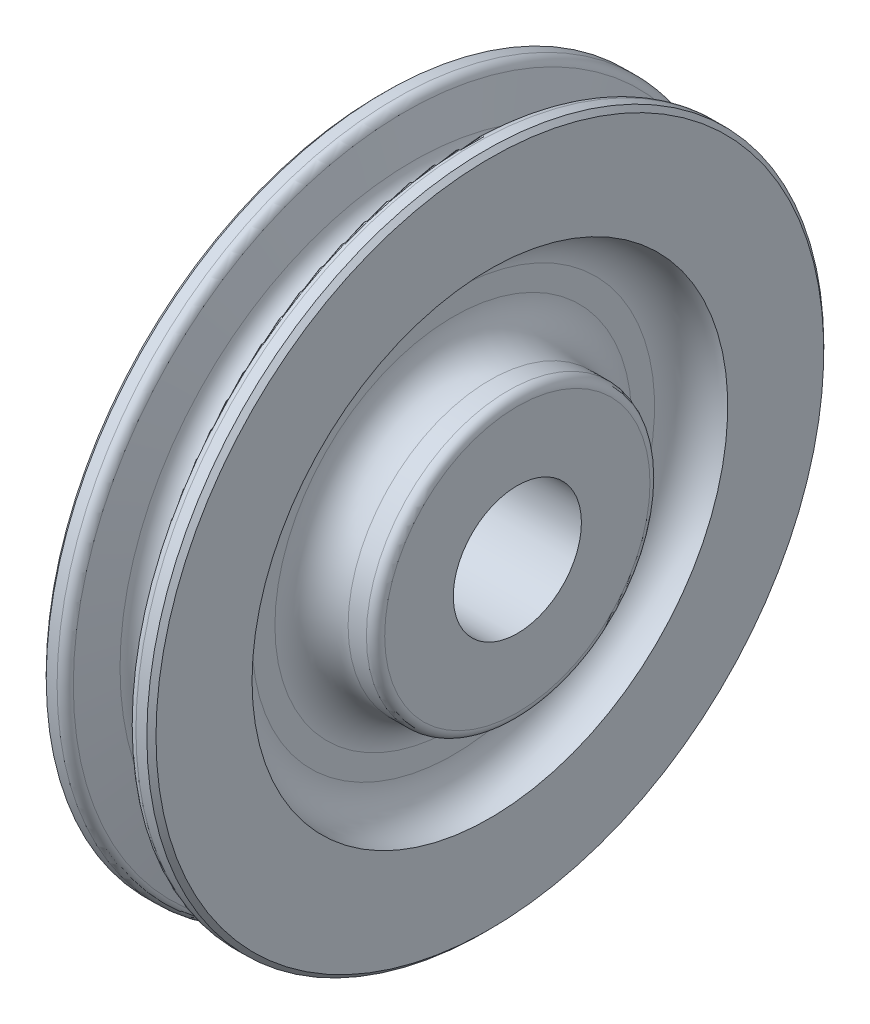
from build123d import *

# Parameters (mm, degrees)
SKETCH2_R          = 11.11885
CUT_EXTRUDE1_DEPTH = 29.575


with BuildPart() as part:
    # Sketch1 → Revolve1 (revolve)
    with BuildSketch(Plane.XY, mode=Mode.PRIVATE) as revolve1_sk:
        with BuildLine():
            Line((-14.2875, 0), (14.2875, 0))
            Line((14.2875, 0), (14.2875, 23.01875))
            ThreePointArc((14.2875, 23.01875), (13.822532015, 24.141282015), (12.7, 24.60625))
            Line((12.7, 24.60625), (9.525, 24.60625))
            ThreePointArc((9.525, 24.60625), (5.034871939, 26.466121939), (3.175, 30.95625))
            Line((3.175, 30.95625), (3.175, 34.925))
            ThreePointArc((3.175, 34.925), (5.034871939, 39.415128061), (9.525, 41.275))
            Line((9.525, 41.275), (9.525, 57.94375))
            Line((9.525, 57.94375), (8.73125, 58.7375))
            Line((8.73125, 58.7375), (6.844883585, 58.7375))
            ThreePointArc((6.844883585, 58.7375), (5.844383855, 58.382540685), (5.291300439, 57.476398003))
            Line((5.291300439, 57.476398003), (3.883957867, 50.777754993))
            ThreePointArc((3.883957867, 50.777754993), (0, 47.625), (-3.883957867, 50.777754993))
            Line((-3.883957867, 50.777754993), (-5.291300439, 57.476398003))
            ThreePointArc((-5.291300439, 57.476398003), (-5.844383855, 58.382540685), (-6.844883585, 58.7375))
            Line((-6.844883585, 58.7375), (-8.73125, 58.7375))
            Line((-8.73125, 58.7375), (-9.525, 57.94375))
            Line((-9.525, 57.94375), (-9.525, 41.275))
            ThreePointArc((-9.525, 41.275), (-5.034871939, 39.415128061), (-3.175, 34.925))
            Line((-3.175, 34.925), (-3.175, 30.95625))
            ThreePointArc((-3.175, 30.95625), (-5.034871939, 26.466121939), (-9.525, 24.60625))
            Line((-9.525, 24.60625), (-12.7, 24.60625))
            ThreePointArc((-12.7, 24.60625), (-13.822532015, 24.141282015), (-14.2875, 23.01875))
            Line((-14.2875, 23.01875), (-14.2875, 0))
        make_face()
    revolve(revolve1_sk.sketch.rotate(Axis((-14.2875, 0, 0), (1, 0, 0)), 90), axis=Axis((-14.2875, 0, 0), (1, 0, 0)))  # turned: the seam where the file's is

    # Sketch2 → Cut-Extrude1 (cut, through all)
    with BuildSketch(Plane(origin=(14.2875, 0, 0), x_dir=(0, 0, -1), z_dir=(1, 0, 0))):
        Circle(SKETCH2_R)
    extrude(amount=-CUT_EXTRUDE1_DEPTH, mode=Mode.SUBTRACT)


solid = part.part
